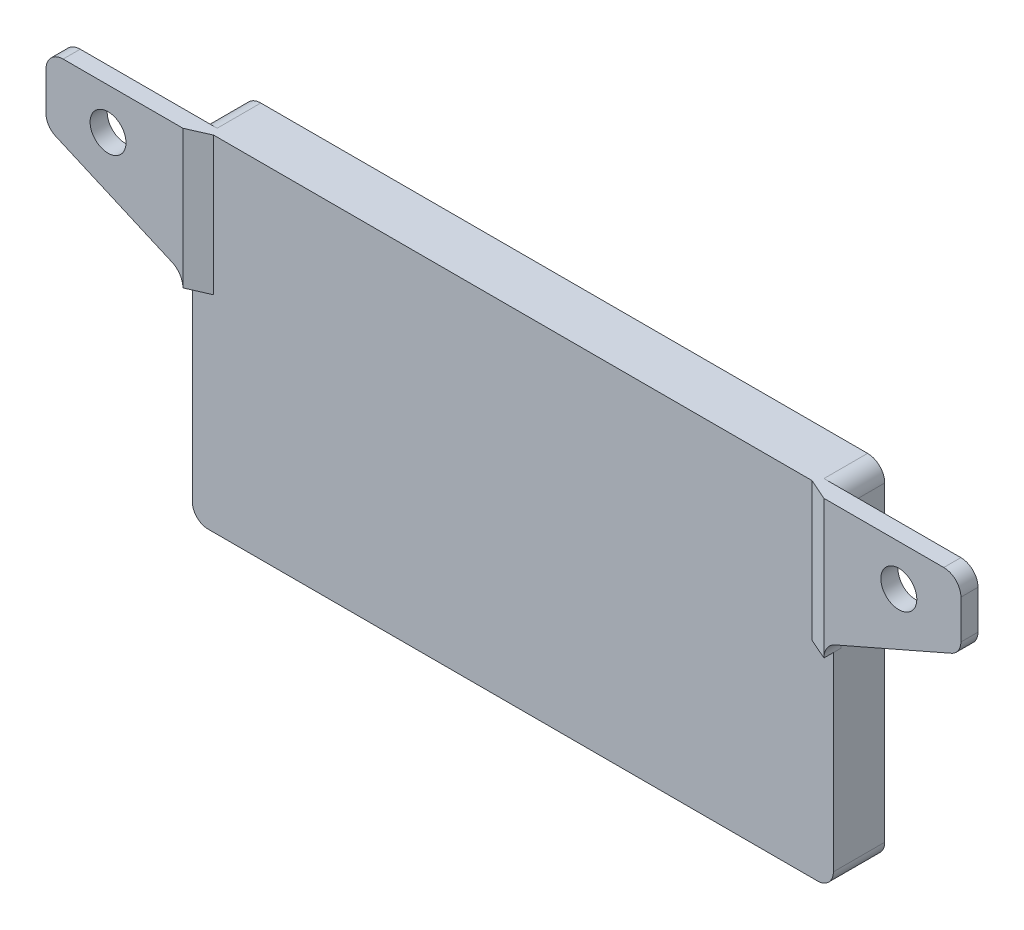
from build123d import *

# Parameters (mm, degrees)
BOSS_EXTRUDE1_DEPTH = 5.1
SKETCH2_R           = 2.1
BOSS_EXTRUDE2_DEPTH = 0.9
FILLET1_R           = 2
SKETCH3_R           = 2.1
BOSS_EXTRUDE3_DEPTH = 1.1
BOSS_EXTRUDE4_DEPTH = 16.158031


with BuildPart() as part:
    # Sketch1 → Boss-Extrude1 (new body)
    with BuildSketch(Plane.XY):
        with BuildLine():
            Line((99.95, 149.85), (25.05, 149.85))
            Line((25.05, 149.85), (25.05, 148))
            Line((25.05, 148), (25.05, 111.5))
            ThreePointArc((25.05, 111.5), (25.591852455, 110.191852455), (26.9, 109.65))
            Line((26.9, 109.65), (98.1, 109.65))
            ThreePointArc((98.1, 109.65), (99.408147545, 110.191852455), (99.95, 111.5))
            Line((99.95, 111.5), (99.95, 148))
            Line((99.95, 148), (99.95, 149.85))
        make_face()
    extrude(amount=BOSS_EXTRUDE1_DEPTH)

    # Sketch2 → Boss-Extrude2 (add)
    with BuildSketch(Plane.XY.offset(5.1)):
        with BuildLine():
            Line((102.1, 149.85), (22.9, 149.85))
            Line((22.9, 149.85), (9.05, 149.85))
            Line((9.05, 149.85), (9.05, 148))
            Line((9.05, 148), (9.05, 143.30803115))
            ThreePointArc((9.05, 143.30803115), (9.351726371, 142.295436082), (10.158485157, 141.61314008))
            Line((10.158485157, 141.61314008), (23.761760493, 135.66170712))
            ThreePointArc((23.761760493, 135.66170712), (24.699345028, 134.868768523), (25.05, 133.69196885))
            Line((25.05, 133.69196885), (25.05, 111.5))
            ThreePointArc((25.05, 111.5), (25.591852455, 110.191852455), (26.9, 109.65))
            Line((26.9, 109.65), (98.1, 109.65))
            ThreePointArc((98.1, 109.65), (99.408147545, 110.191852455), (99.95, 111.5))
            Line((99.95, 111.5), (99.95, 133.69196885))
            ThreePointArc((99.95, 133.69196885), (100.300654972, 134.868768523), (101.238239507, 135.66170712))
            Line((101.238239507, 135.66170712), (114.841514843, 141.61314008))
            ThreePointArc((114.841514843, 141.61314008), (115.648273629, 142.295436082), (115.95, 143.30803115))
            Line((115.95, 143.30803115), (115.95, 148))
            Line((115.95, 148), (115.95, 149.85))
            Line((115.95, 149.85), (102.1, 149.85))
        make_face()
        with Locations((16.3, 145.05)):
            Circle(SKETCH2_R, mode=Mode.SUBTRACT)
        with Locations((108.7, 145.05)):
            Circle(SKETCH2_R, mode=Mode.SUBTRACT)
    extrude(amount=BOSS_EXTRUDE2_DEPTH)

    # Fillet1
    fillet1_edges = [part.edges().sort_by_distance(p)[0] for p in [
        (25.05, 149.85, 2.55),
        (99.95, 149.85, 2.55),
        (115.95, 149.85, 5.55),
        (9.05, 149.85, 5.55),
    ]]
    fillet(fillet1_edges, radius=FILLET1_R)

    # Sketch3 → Boss-Extrude3 (add)
    with BuildSketch(Plane.XY.offset(6)):
        with BuildLine():
            Line((99.95, 133.69196885), (99.95, 149.85))
            Line((99.95, 149.85), (113.95, 149.85))
            ThreePointArc((113.95, 149.85), (115.364213562, 149.264213562), (115.95, 147.85))
            Line((115.95, 147.85), (115.95, 143.30803115))
            ThreePointArc((115.95, 143.30803115), (115.648273629, 142.295436082), (114.841514843, 141.61314008))
            Line((114.841514843, 141.61314008), (101.238239507, 135.66170712))
            ThreePointArc((101.238239507, 135.66170712), (100.300654972, 134.868768523), (99.95, 133.69196885))
        make_face()
        with Locations((108.7, 145.05)):
            Circle(SKETCH3_R, mode=Mode.SUBTRACT)
        with BuildLine():
            Line((11.05, 149.85), (25.05, 149.85))
            Line((25.05, 149.85), (25.05, 133.69196885))
            ThreePointArc((25.05, 133.69196885), (24.699345028, 134.868768523), (23.761760493, 135.66170712))
            Line((23.761760493, 135.66170712), (10.158485157, 141.61314008))
            ThreePointArc((10.158485157, 141.61314008), (9.351726371, 142.295436082), (9.05, 143.30803115))
            Line((9.05, 143.30803115), (9.05, 147.85))
            ThreePointArc((9.05, 147.85), (9.635786438, 149.264213562), (11.05, 149.85))
        make_face()
        with Locations((16.3, 145.05)):
            Circle(SKETCH3_R, mode=Mode.SUBTRACT)
    extrude(amount=BOSS_EXTRUDE3_DEPTH)

    # Sketch4 → Boss-Extrude4 (add)
    with BuildSketch(Plane(origin=(0, 149.85, 0), x_dir=(1, 0, 0), z_dir=(0, 1, 0))):
        Polygon((25.05, -7.1), (27.55, -6), (25.05, -6), align=None)
        Polygon((97.45, -6), (99.95, -7.1), (99.95, -6), align=None)
    extrude(amount=-BOSS_EXTRUDE4_DEPTH)


solid = part.part
